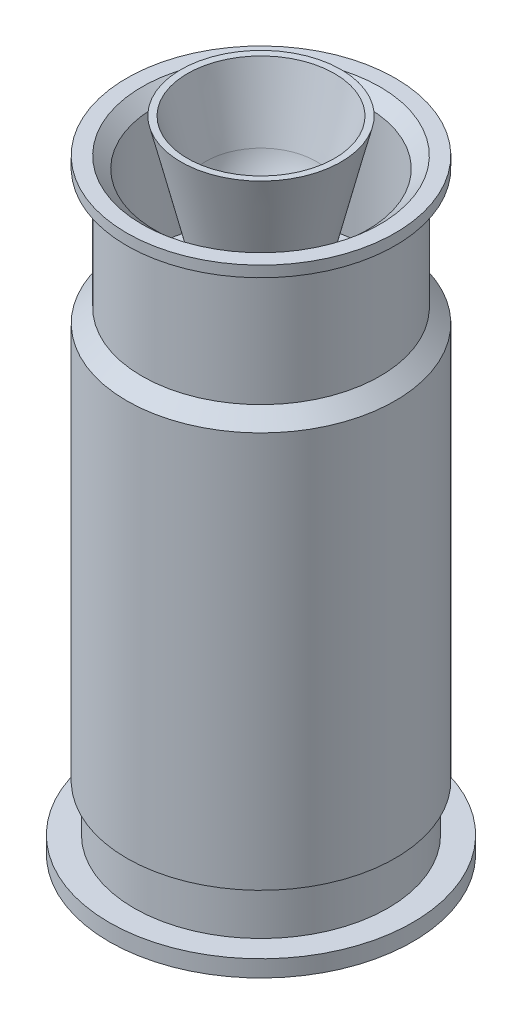
from build123d import *


with BuildPart() as part:
    # Sketch1 → Revolve1 (revolve)
    with BuildSketch(Plane.XY):
        with BuildLine():
            Line((0, 0), (92.96, 0))
            Line((92.96, 0), (92.96, 10.2))
            Line((92.96, 10.2), (77.766, 10.2))
            Line((77.766, 10.2), (77.766, 38.9))
            Line((77.766, 38.9), (82.206, 38.9))
            Line((82.206, 38.9), (82.206, 281.51))
            Line((82.206, 281.51), (72.906, 289.93))
            Line((72.906, 289.93), (72.906, 358.4))
            Line((72.906, 358.4), (82.206, 363.8))
            Line((82.206, 363.8), (82.206, 370.5))
            Line((82.206, 370.5), (72.906, 370.5))
            Line((72.906, 370.5), (65.0875, 363.5375))
            Line((65.0875, 363.5375), (65.0875, 289.93))
            Line((65.0875, 289.93), (24.298190419, 289.93))
            Line((24.298190419, 289.93), (49.045, 391.622879584))
            Line((49.045, 391.622879584), (45.045, 391.5))
            Line((45.045, 391.5), (33.78053484, 350.560926443))
            ThreePointArc((33.78053484, 350.560926443), (27.675249702, 336.006994767), (17.337709758, 324.081111078))
            ThreePointArc((17.337709758, 324.081111078), (10.310411687, 295.362914191), (35.586293569, 280.025132548))
            Line((35.586293569, 280.025132548), (77.766, 275.321756158))
            Line((77.766, 275.321756158), (77.766, 47.2311364))
            Line((77.766, 47.2311364), (73.766, 43.2311364))
            Line((73.766, 43.2311364), (73.766, 4))
            Line((73.766, 4), (0, 4))
            Line((0, 4), (0, 0))
        make_face()
        Polygon((8.4074, 10.2), (67.07869918, 10.2), (73.025, 53.975), (73.025, 273.05), (8.4074, 281.827514286), align=None)
    revolve(axis=Axis((0, 0, 0), (0, 1, 0)))


solid = part.part
